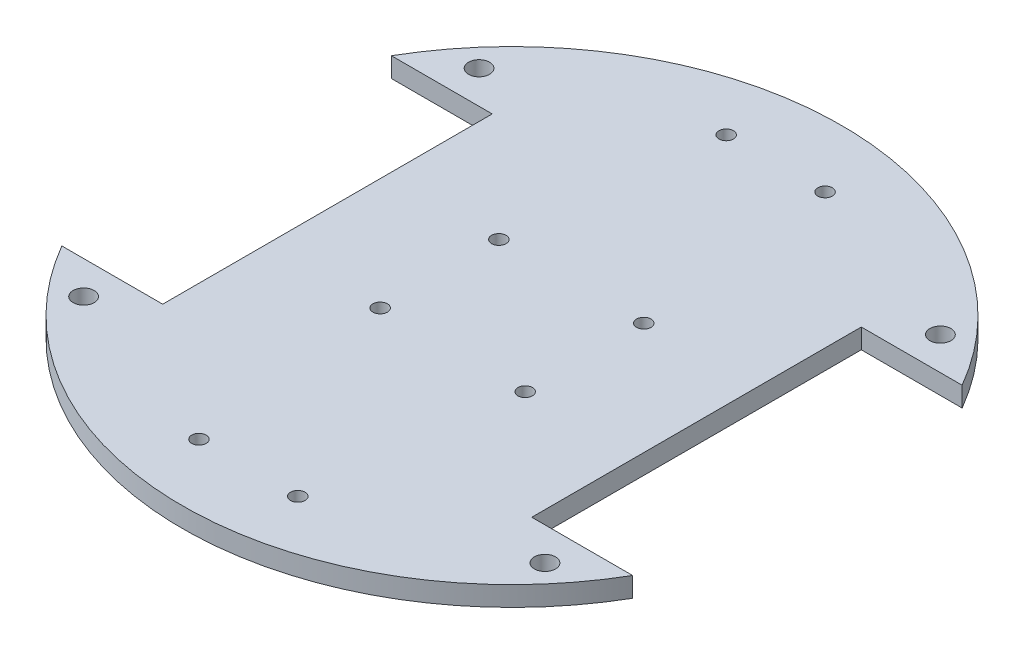
from build123d import *

# Parameters (mm, degrees)
SKETCH1_R           = 1.1
SKETCH1_R_2         = 1.6
BOSS_EXTRUDE1_DEPTH = 3


with BuildPart() as part:
    # Sketch1 → Boss-Extrude1 (new body)
    with BuildSketch(Plane(origin=(0, 0, 0), x_dir=(1, 0, 0), z_dir=(0, 1, 0))):
        with BuildLine():
            Line((-28, 25), (-28, -25))
            Line((-28, -25), (-43.301270189, -25))
            ThreePointArc((-43.301270189, -25), (0, -50), (43.301270189, -25))
            Line((43.301270189, -25), (28, -25))
            Line((28, -25), (28, 25))
            Line((28, 25), (43.301270189, 25))
            ThreePointArc((43.301270189, 25), (0, 50), (-43.301270189, 25))
            Line((-43.301270189, 25), (-28, 25))
        make_face()
        with Locations((-11, 9)):
            Circle(SKETCH1_R, mode=Mode.SUBTRACT)
        with Locations((-7.5, 40)):
            Circle(SKETCH1_R, mode=Mode.SUBTRACT)
        with Locations((-7.5, -40)):
            Circle(SKETCH1_R, mode=Mode.SUBTRACT)
        with Locations((-11, -9)):
            Circle(SKETCH1_R, mode=Mode.SUBTRACT)
        with Locations((7.5, -40)):
            Circle(SKETCH1_R, mode=Mode.SUBTRACT)
        with Locations((7.5, 40)):
            Circle(SKETCH1_R, mode=Mode.SUBTRACT)
        with Locations((11, 9)):
            Circle(SKETCH1_R, mode=Mode.SUBTRACT)
        with Locations((11, -9)):
            Circle(SKETCH1_R, mode=Mode.SUBTRACT)
        with Locations((-35, 30)):
            Circle(SKETCH1_R_2, mode=Mode.SUBTRACT)
        with Locations((-35, -30)):
            Circle(SKETCH1_R_2, mode=Mode.SUBTRACT)
        with Locations((35, 30)):
            Circle(SKETCH1_R_2, mode=Mode.SUBTRACT)
        with Locations((35, -30)):
            Circle(SKETCH1_R_2, mode=Mode.SUBTRACT)
    extrude(amount=BOSS_EXTRUDE1_DEPTH)


solid = part.part
